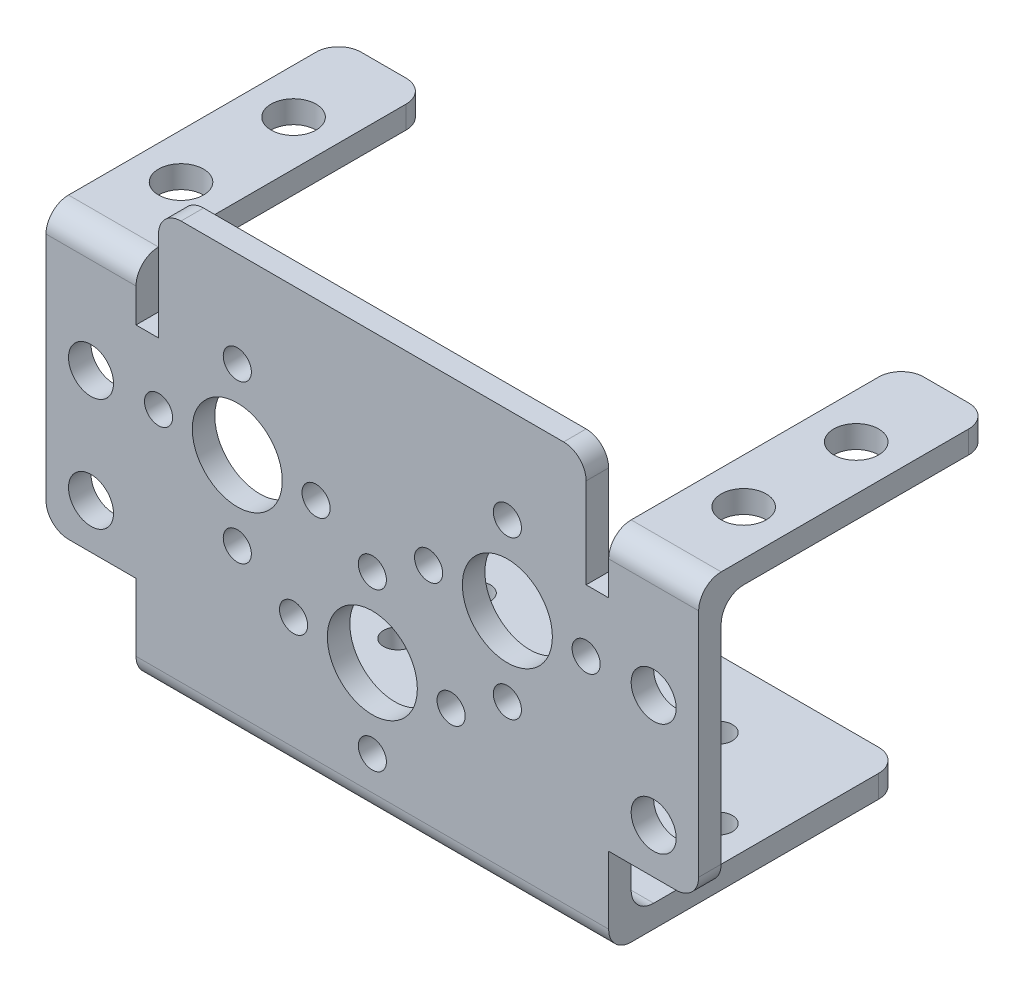
from build123d import *

# Parameters (mm, degrees)
SKETCH_1_W      = 42
SKETCH_1_H      = 26
SKETCH_1_R      = 1.25
EXTRUDE_1_DEPTH = 2
SKETCH_2_R      = 4
SKETCH_2_R_2    = 1.25
SKETCH_2_R_3    = 2
EXTRUDE_2_DEPTH = 2
SKETCH_3_W      = 8
SKETCH_3_H      = 26
SKETCH_3_R      = 2
EXTRUDE_3_DEPTH = 2
FILLET_1_R      = 2


with BuildPart() as part:
    # 草图1 → 凸台-拉伸1 (new body)
    with BuildSketch(Plane(origin=(0, 0, 0), x_dir=(1, 0, 0), z_dir=(0, 1, 0))):
        Rectangle(SKETCH_1_W, SKETCH_1_H)
        with Locations((10.75, 0)):
            Circle(SKETCH_1_R, mode=Mode.SUBTRACT)
        with Locations((3.75, 0)):
            Circle(SKETCH_1_R, mode=Mode.SUBTRACT)
        with Locations((10.75, 7)):
            Circle(SKETCH_1_R, mode=Mode.SUBTRACT)
        with Locations((17.75, 0)):
            Circle(SKETCH_1_R, mode=Mode.SUBTRACT)
        with Locations((10.75, -7)):
            Circle(SKETCH_1_R, mode=Mode.SUBTRACT)
        with Locations((-10.75, -7)):
            Circle(SKETCH_1_R, mode=Mode.SUBTRACT)
        with Locations((-17.75, 0)):
            Circle(SKETCH_1_R, mode=Mode.SUBTRACT)
        with Locations((-10.75, 0)):
            Circle(SKETCH_1_R, mode=Mode.SUBTRACT)
        with Locations((-10.75, 7)):
            Circle(SKETCH_1_R, mode=Mode.SUBTRACT)
        with Locations((-3.75, 0)):
            Circle(SKETCH_1_R, mode=Mode.SUBTRACT)
    extrude(amount=EXTRUDE_1_DEPTH)

    # 草图2 → 凸台-拉伸2 (add)
    with BuildSketch(Plane.XY.offset(13)):
        Polygon((21, 0), (-21, 0), (-21, 8), (-29, 8), (-29, 32.5), (-21, 32.5), (-21, 27.5), (-19, 27.5), (-19, 37.5), (0, 37.5), (19, 37.5), (19, 27.5), (21, 27.5), (21, 32.5), (29, 32.5), (29, 8), (21, 8), align=None)
        with Locations((0, 12)):
            Circle(SKETCH_2_R, mode=Mode.SUBTRACT)
        with Locations((0, 19)):
            Circle(SKETCH_2_R_2, mode=Mode.SUBTRACT)
        with Locations((7, 12)):
            Circle(SKETCH_2_R_2, mode=Mode.SUBTRACT)
        with Locations((0, 5)):
            Circle(SKETCH_2_R_2, mode=Mode.SUBTRACT)
        with Locations((-7, 12)):
            Circle(SKETCH_2_R_2, mode=Mode.SUBTRACT)
        with Locations((12, 22)):
            Circle(SKETCH_2_R, mode=Mode.SUBTRACT)
        with Locations((12, 29)):
            Circle(SKETCH_2_R_2, mode=Mode.SUBTRACT)
        with Locations((19, 22)):
            Circle(SKETCH_2_R_2, mode=Mode.SUBTRACT)
        with Locations((12, 15)):
            Circle(SKETCH_2_R_2, mode=Mode.SUBTRACT)
        with Locations((5, 22)):
            Circle(SKETCH_2_R_2, mode=Mode.SUBTRACT)
        with Locations((-19, 22)):
            Circle(SKETCH_2_R_2, mode=Mode.SUBTRACT)
        with Locations((-12, 15)):
            Circle(SKETCH_2_R_2, mode=Mode.SUBTRACT)
        with Locations((-12, 22)):
            Circle(SKETCH_2_R, mode=Mode.SUBTRACT)
        with Locations((-5, 22)):
            Circle(SKETCH_2_R_2, mode=Mode.SUBTRACT)
        with Locations((-12, 29)):
            Circle(SKETCH_2_R_2, mode=Mode.SUBTRACT)
        with Locations((-25, 22)):
            Circle(SKETCH_2_R_3, mode=Mode.SUBTRACT)
        with Locations((-25, 12)):
            Circle(SKETCH_2_R_3, mode=Mode.SUBTRACT)
        with Locations((25, 12)):
            Circle(SKETCH_2_R_3, mode=Mode.SUBTRACT)
        with Locations((25, 22)):
            Circle(SKETCH_2_R_3, mode=Mode.SUBTRACT)
    extrude(amount=-EXTRUDE_2_DEPTH)

    # 草图3 → 凸台-拉伸3 (add)
    with BuildSketch(Plane(origin=(0, 32.5, 0), x_dir=(1, 0, 0), z_dir=(0, 1, 0))):
        with Locations((-25, 0)):
            Rectangle(SKETCH_3_W, SKETCH_3_H)
        with Locations((-25, 5)):
            Circle(SKETCH_3_R, mode=Mode.SUBTRACT)
        with Locations((-25, -5)):
            Circle(SKETCH_3_R, mode=Mode.SUBTRACT)
        with Locations((25, 0)):
            Rectangle(SKETCH_3_W, SKETCH_3_H)
        with Locations((25, -5)):
            Circle(SKETCH_3_R, mode=Mode.SUBTRACT)
        with Locations((25, 5)):
            Circle(SKETCH_3_R, mode=Mode.SUBTRACT)
    extrude(amount=-EXTRUDE_3_DEPTH)

    # 圆角1
    fillet_1_edges = [part.edges().sort_by_distance(p)[0] for p in [
        (-25, 30.5, 11),
        (-29, 31.5, -13),
        (-21, 31.5, -13),
        (25, 30.5, 11),
        (21, 31.5, -13),
        (29, 31.5, -13),
        (0, 0, 13),
        (-29, 8, 12),
        (-19, 37.5, 12),
        (19, 37.5, 12),
        (29, 8, 12),
        (0, 2, 11),
        (25, 32.5, 13),
        (-25, 32.5, 13),
        (-21, 1, -13),
        (21, 1, -13),
    ]]
    fillet(fillet_1_edges, radius=FILLET_1_R)


solid = part.part
